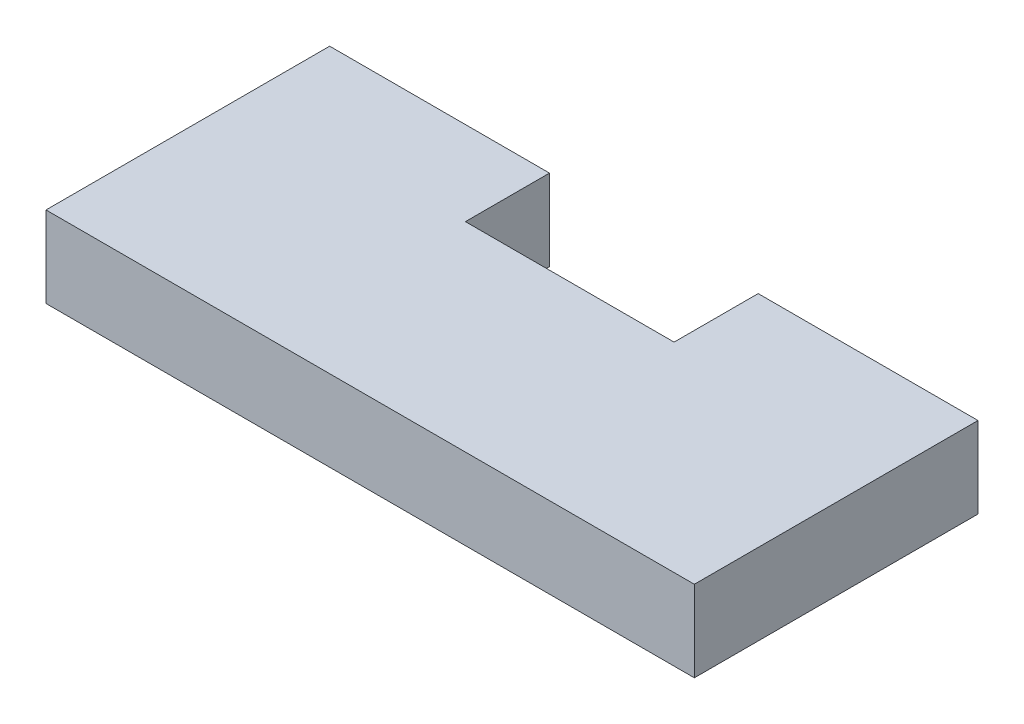
from build123d import *

# Parameters (mm, degrees)
BOSS_EXTRU_1_DEPTH = 4


with BuildPart() as part:
    # Esquisse1 → Boss.-Extru.1 (new body)
    with BuildSketch(Plane(origin=(0, 0, 0), x_dir=(1, 0, 0), z_dir=(0, 1, 0))):
        Polygon((-16, 0), (16, 0), (16, 14), (5.15, 14), (5.15, 9.85), (-5.15, 9.85), (-5.15, 14), (-16, 14), align=None)
    extrude(amount=BOSS_EXTRU_1_DEPTH)


solid = part.part
